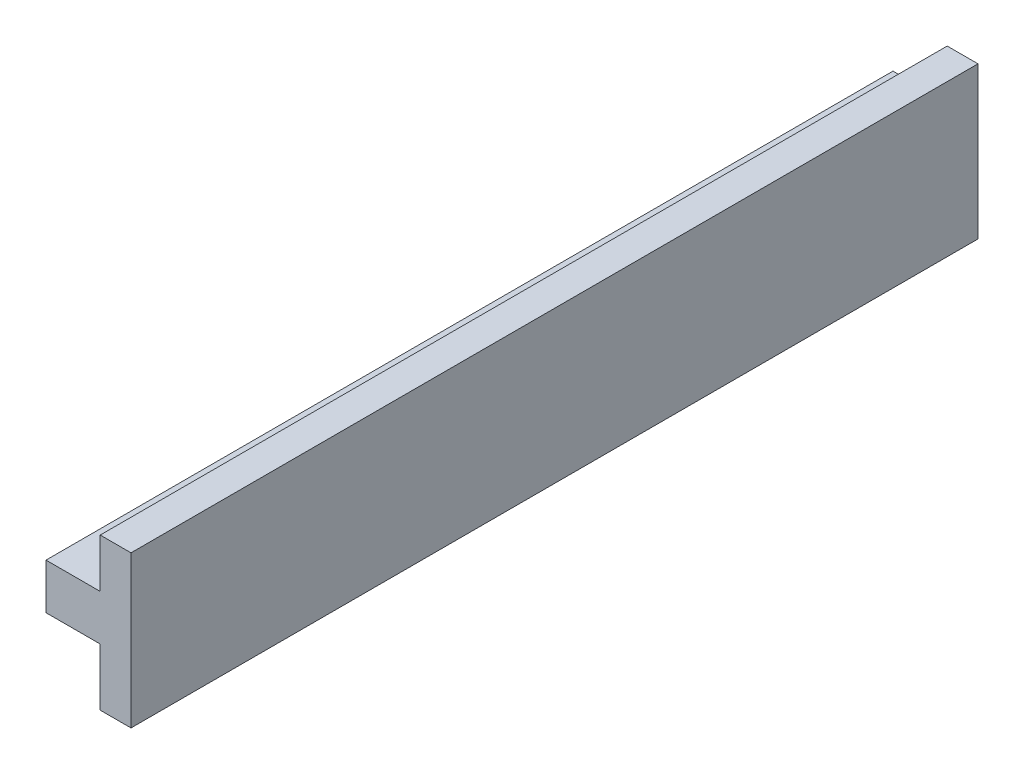
from build123d import *

# Parameters (mm, degrees)
EXTRUDE2_DEPTH = 137.5


with BuildPart() as part:
    # Sketch1 → Extrude2 (new body)
    with BuildSketch(Plane.XY.offset(-35.173777659)):
        Polygon((85.961408719, 43.751957214), (94.761408719, 43.751957214), (94.761408719, 51.676244301), (99.761408719, 51.676244301), (99.761408719, 27.051957214), (94.761408719, 27.051957214), (94.761408719, 36.351957214), (85.961408719, 36.351957214), align=None)
    extrude(amount=-EXTRUDE2_DEPTH)


solid = part.part
